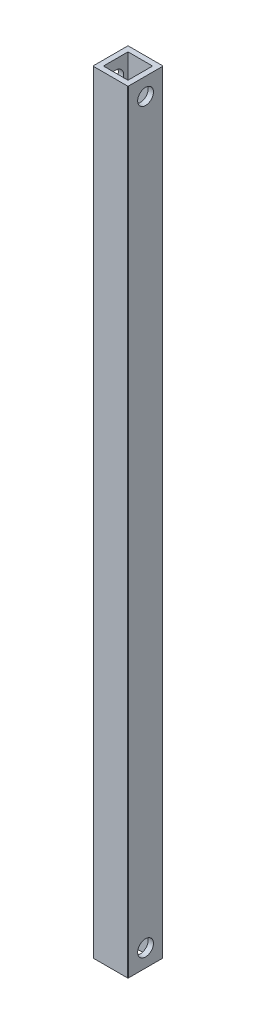
from build123d import *

# Parameters (mm, degrees)
SKETCH1_W               = 10
SKETCH1_H               = 10
SKETCH1_W_2             = 7
SKETCH1_H_2             = 7
EXTRUDE_THIN1_DEPTH     = 220
SKETCH2_R               = 2.25
CUT_EXTRUDE1_DEPTH      = 6
CUT_EXTRUDE1_DEPTH_BACK = 6
FILLET1_R               = 0.2


with BuildPart() as part:
    # Sketch1 → Extrude-Thin1 (new body)
    with BuildSketch(Plane(origin=(0, 0, 0), x_dir=(1, 0, 0), z_dir=(0, 1, 0))):
        Rectangle(SKETCH1_W, SKETCH1_H)
        Rectangle(SKETCH1_W_2, SKETCH1_H_2, mode=Mode.SUBTRACT)
    extrude(amount=EXTRUDE_THIN1_DEPTH)

    # Sketch2 → Cut-Extrude1 (cut, two sides)
    with BuildSketch(Plane(origin=(0, 0, 0), x_dir=(0, 0, -1), z_dir=(1, 0, 0))) as cut_extrude1_sk:
        with Locations((0, 215)):
            Circle(SKETCH2_R)
        with Locations((0, 5)):
            Circle(SKETCH2_R)
    extrude(amount=CUT_EXTRUDE1_DEPTH, mode=Mode.SUBTRACT)
    extrude(cut_extrude1_sk.sketch, amount=-CUT_EXTRUDE1_DEPTH_BACK, mode=Mode.SUBTRACT)

    # Fillet1
    fillet1_edges = [part.edges().sort_by_distance(p)[0] for p in [
        (-5, 110, -5),
        (5, 110, -5),
        (5, 110, 5),
        (-5, 110, 5),
    ]]
    fillet(fillet1_edges, radius=FILLET1_R)


solid = part.part
